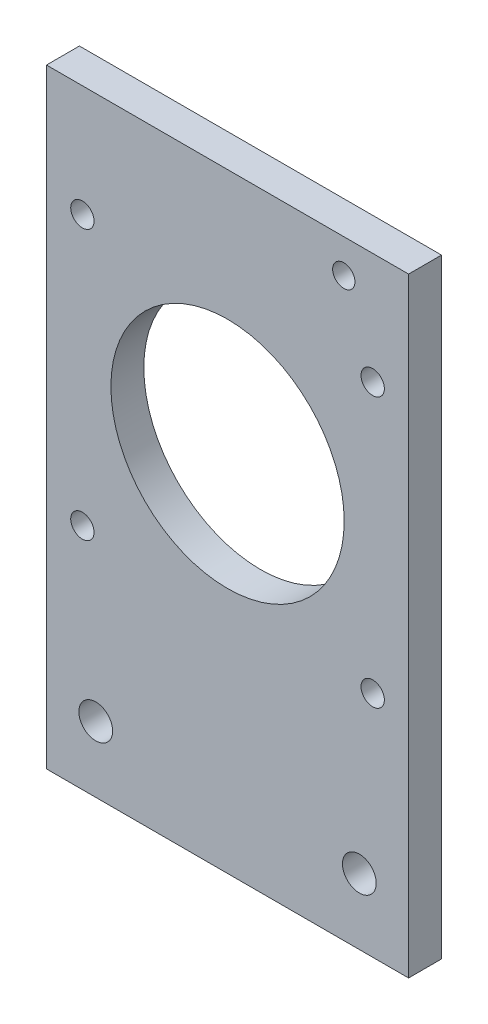
from build123d import *

# Parameters (mm, degrees)
SKETCH2_R               = 22.5
BOSS_EXTRUDE1_DEPTH     = 3.175
SKETCH3_R               = 3.25755
SKETCH3_R_2             = 2.15
CUT_EXTRUDE1_DEPTH      = 1
CUT_EXTRUDE1_DEPTH_BACK = 7.35
SKETCH4_R               = 2.25
CUT_EXTRUDE2_DEPTH      = 10


with BuildPart() as part:
    # Sketch2 → Boss-Extrude1 (new body, symmetric)
    with BuildSketch(Plane.XY):
        Polygon((-34.925, 0), (34.925, 0), (34.925, 70.1), (34.925, 102.6), (34.925, 117.6), (-34.925, 117.6), (-34.925, 102.6), (-34.925, 70.1), align=None)
        with Locations((0, 70.1)):
            Circle(SKETCH2_R, mode=Mode.SUBTRACT)
    extrude(amount=BOSS_EXTRUDE1_DEPTH, both=True)

    # Sketch3 → Cut-Extrude1 (cut, two sides)
    with BuildSketch(Plane.XY.offset(3.175)) as cut_extrude1_sk:
        with Locations((-25.425, 12.7)):
            Circle(SKETCH3_R)
        with Locations((25.425, 12.7)):
            Circle(SKETCH3_R)
        with Locations((22.425, 111.1)):
            Circle(SKETCH3_R_2)
    extrude(amount=CUT_EXTRUDE1_DEPTH, mode=Mode.SUBTRACT)
    extrude(cut_extrude1_sk.sketch, amount=-CUT_EXTRUDE1_DEPTH_BACK, mode=Mode.SUBTRACT)

    # Sketch4 → Cut-Extrude2 (cut)
    with BuildSketch(Plane.XY.offset(3.175)):
        with Locations((28, 96.1)):
            Circle(SKETCH4_R)
        with Locations((-28, 44.1)):
            Circle(SKETCH4_R)
        with Locations((28, 44.1)):
            Circle(SKETCH4_R)
        with Locations((-28, 96.1)):
            Circle(SKETCH4_R)
    extrude(amount=-CUT_EXTRUDE2_DEPTH, mode=Mode.SUBTRACT)


solid = part.part
